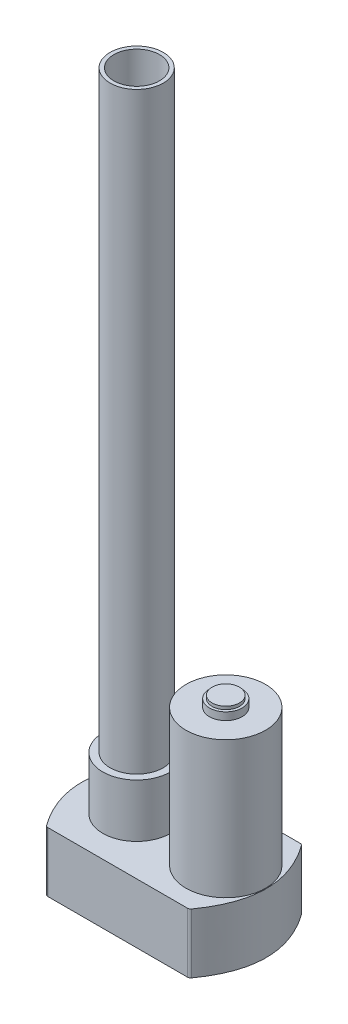
from build123d import *

# Parameters (mm, degrees)
BOSS_EXTRUDE3_DEPTH      = 25
BOSS_EXTRUDE3_DEPTH_BACK = 14.3
SKETCH6_R                = 26.15
BOSS_EXTRUDE4_DEPTH      = 90
SKETCH7_R                = 10.75
SKETCH7_R_2              = 8.15
BOSS_EXTRUDE5_DEPTH      = 5
SKETCH8_R                = 9
BOSS_EXTRUDE6_DEPTH      = 7
SKETCH9_R                = 22.25
SKETCH9_R_2              = 17.5
SKETCH9_R_3              = 26.15
BOSS_EXTRUDE7_DEPTH      = 35
SKETCH10_R               = 17.5
SKETCH10_R_2             = 15
BOSS_EXTRUDE8_DEPTH      = 425
FILLET1_R                = 2


with BuildPart() as part:
    # Sketch5 → Boss-Extrude3 (new body, two sides)
    with BuildSketch(Plane(origin=(0, 0, 0), x_dir=(1, 0, 0), z_dir=(0, 1, 0))) as boss_extrude3_sk:
        with BuildLine():
            Line((-52, -32), (42, -32))
            add(Edge.make_bspline(
                [(42, 42), (69.3, 5), (42, -32)],
                knots=[0, 0, 0, 1, 1, 1], degree=2))
            Line((42, 42), (-52, 42))
            add(Edge.make_bspline(
                [(-52, 42), (-79.3, 5), (-52, -32)],
                knots=[0, 0, 0, 1, 1, 1], degree=2))
        make_face()
    extrude(amount=BOSS_EXTRUDE3_DEPTH)
    extrude(boss_extrude3_sk.sketch, amount=-BOSS_EXTRUDE3_DEPTH_BACK)

    # Sketch6 → Boss-Extrude4 (add)
    with BuildSketch(Plane(origin=(0, 25, 0), x_dir=(1, 0, 0), z_dir=(0, 1, 0))):
        with Locations((29.05, 5)):
            Circle(SKETCH6_R)
    extrude(amount=BOSS_EXTRUDE4_DEPTH)

    # Sketch7 → Boss-Extrude5 (add)
    with BuildSketch(Plane(origin=(0, 115, 0), x_dir=(1, 0, 0), z_dir=(0, 1, 0))):
        with Locations((29.05, 5)):
            Circle(SKETCH7_R)
        with Locations((29.05, 5)):
            Circle(SKETCH7_R_2, mode=Mode.SUBTRACT)
    extrude(amount=BOSS_EXTRUDE5_DEPTH)

    # Sketch8 → Boss-Extrude6 (add)
    with BuildSketch(Plane(origin=(0, 115, 0), x_dir=(1, 0, 0), z_dir=(0, 1, 0))):
        with Locations((29.05, 5)):
            Circle(SKETCH8_R)
    extrude(amount=BOSS_EXTRUDE6_DEPTH)

    # Sketch9 → Boss-Extrude7 (add)
    with BuildSketch(Plane(origin=(0, 25, 0), x_dir=(1, 0, 0), z_dir=(0, 1, 0))):
        with Locations((-29.55, 5)):
            Circle(SKETCH9_R)
        with Locations((-29.55, 5)):
            Circle(SKETCH9_R_2, mode=Mode.SUBTRACT)
        with Locations((29.05, 5)):
            Circle(SKETCH9_R_3)
    extrude(amount=BOSS_EXTRUDE7_DEPTH)

    # Sketch10 → Boss-Extrude8 (add)
    with BuildSketch(Plane(origin=(0, 25, 0), x_dir=(1, 0, 0), z_dir=(0, 1, 0))):
        with Locations((-29.55, 5)):
            Circle(SKETCH10_R)
        with Locations((-29.55, 5)):
            Circle(SKETCH10_R_2, mode=Mode.SUBTRACT)
    extrude(amount=BOSS_EXTRUDE8_DEPTH)

    # Fillet1
    fillet1_edges = [part.edges().sort_by_distance(p)[0] for p in [
        (42, 12.5, -42),
        (-52, 12.5, -42),
        (-52, 12.5, 32),
        (42, 12.5, 32),
    ]]
    fillet(fillet1_edges, radius=FILLET1_R)


solid = part.part
